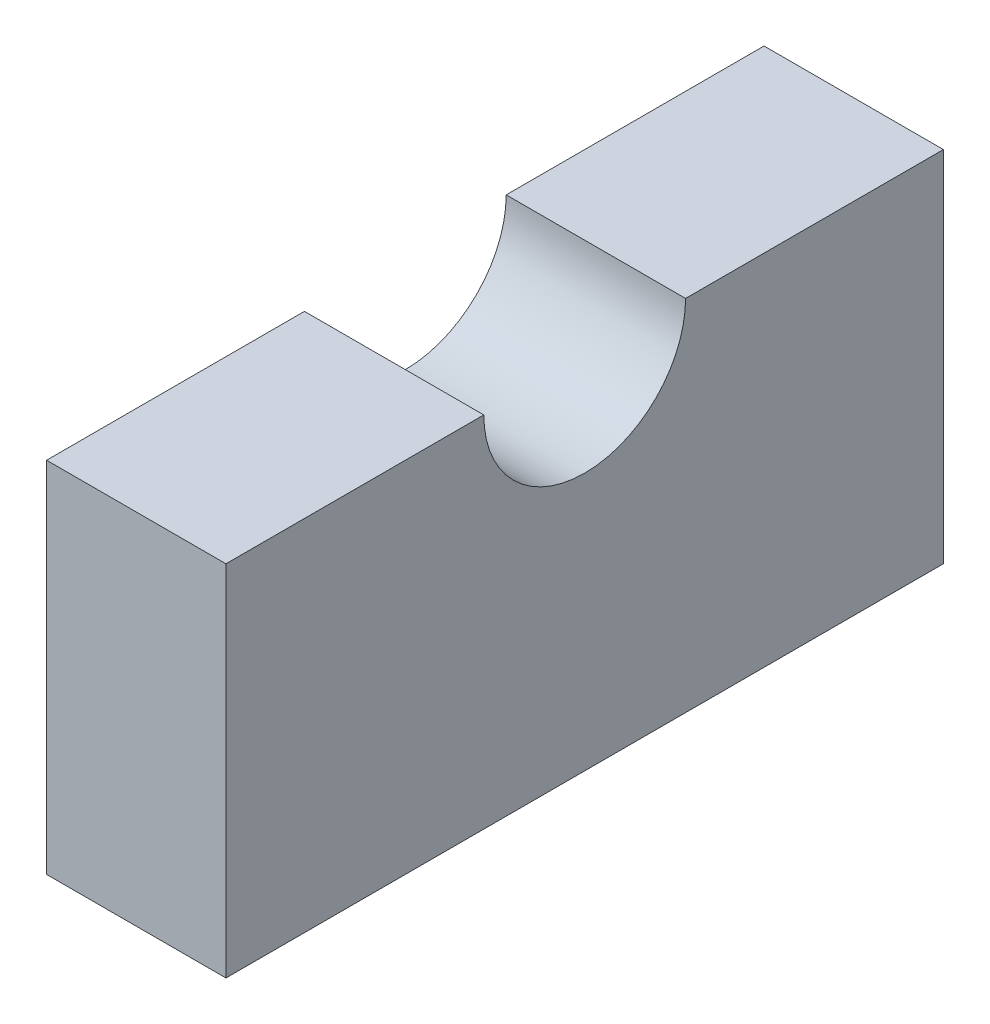
from build123d import *

# Parameters (mm, degrees)
BOSS_EXTRUDE1_DEPTH = 12.7


with BuildPart() as part:
    # Sketch1 → Boss-Extrude1 (new body, symmetric)
    with BuildSketch(Plane(origin=(0, 0, 0), x_dir=(0, 0, -1), z_dir=(1, 0, 0))):
        with BuildLine():
            Line((14.2875, 50.8), (50.8, 50.8))
            Line((50.8, 50.8), (50.8, 0))
            Line((50.8, 0), (-50.8, 0))
            Line((-50.8, 0), (-50.8, 50.8))
            Line((-50.8, 50.8), (-14.2875, 50.8))
            ThreePointArc((-14.2875, 50.8), (0, 36.5125), (14.2875, 50.8))
        make_face()
    extrude(amount=BOSS_EXTRUDE1_DEPTH, both=True)


solid = part.part
